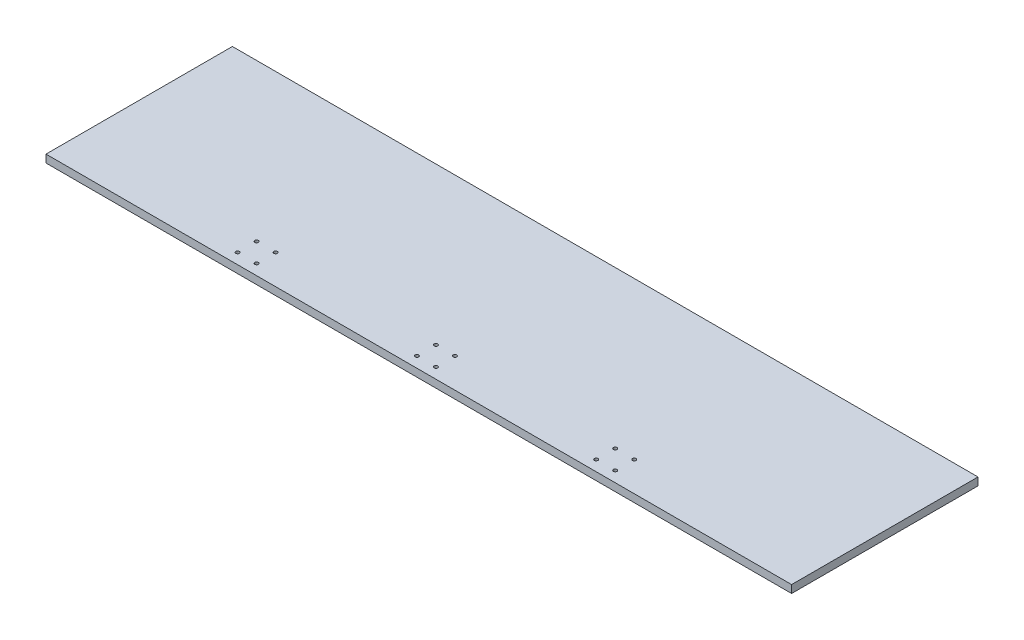
from build123d import *

# Parameters (mm, degrees)
SKETCH1_W              = 609.6
SKETCH1_H              = 152.4
BOSS_EXTRUDE1_DEPTH    = 6.35
M2_5_CLEARANCE_HOLE1_D = 2.9


with BuildPart() as part:
    # Sketch1 → Boss-Extrude1 (new body)
    with BuildSketch(Plane(origin=(0, 0, 0), x_dir=(1, 0, 0), z_dir=(0, 1, 0))):
        Rectangle(SKETCH1_W, SKETCH1_H)
    extrude(amount=BOSS_EXTRUDE1_DEPTH)

    # M2.5 Clearance Hole1 (through all)
    with Locations(Plane(origin=(0, 0, 0), x_dir=(-1, 0, 0), z_dir=(0, -1, 0))):
        with Locations((156.878174593, -51.921825407), (141.321825407, -51.921825407), (141.321825407, -67.478174593), (156.878174593, -67.478174593), (10.278174593, -51.921825407), (10.278174593, -67.478174593), (-5.278174593, -67.478174593), (-5.278174593, -51.921825407), (-136.321825407, -51.921825407), (-136.321825407, -67.478174593), (-151.878174593, -67.478174593), (-151.878174593, -51.921825407)):
            Hole(M2_5_CLEARANCE_HOLE1_D / 2)


solid = part.part
